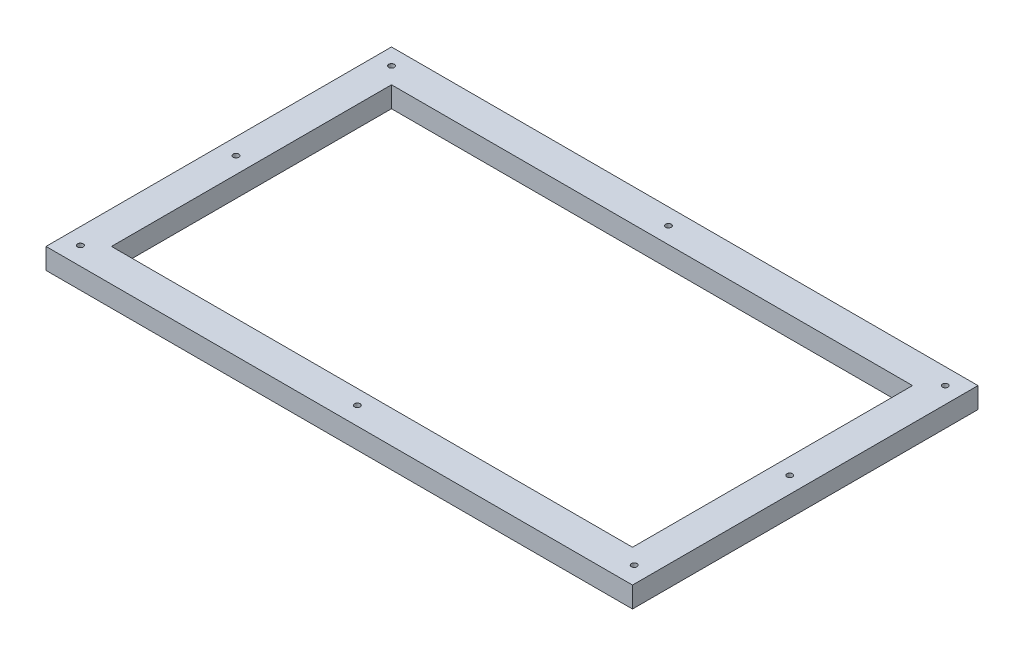
from build123d import *

# Parameters (mm, degrees)
SKETCH1_W                      = 358.27
SKETCH1_H                      = 211.05
BOSS_EXTRUDE1_DEPTH            = 12.7
SKETCH2_W                      = 318.27
SKETCH2_H                      = 171.05
CUT_EXTRUDE1_DEPTH             = 12.7
M3_CLEARANCE_HOLE1_D           = 3.4
M3_CLEARANCE_HOLE1_CSINK_D     = 3.45
M3_CLEARANCE_HOLE1_CSINK_ANGLE = 90


with BuildPart() as part:
    # Sketch1 → Boss-Extrude1 (new body)
    with BuildSketch(Plane(origin=(0, 0, 0), x_dir=(1, 0, 0), z_dir=(0, 1, 0))):
        Rectangle(SKETCH1_W, SKETCH1_H)
    extrude(amount=BOSS_EXTRUDE1_DEPTH)

    # Sketch2 → Cut-Extrude1 (cut)
    with BuildSketch(Plane(origin=(0, 12.7, 0), x_dir=(1, 0, 0), z_dir=(0, 1, 0))):
        Rectangle(SKETCH2_W, SKETCH2_H)
    extrude(amount=-CUT_EXTRUDE1_DEPTH, mode=Mode.SUBTRACT)

    # M3 Clearance Hole1 (through all)
    with Locations(Plane(origin=(0, 12.7, 0), x_dir=(1, 0, 0), z_dir=(0, 1, 0))):
        with Locations((-169.135, 95.525), (-169.135, 0.525), (-169.135, -94.475), (0, -94.475), (169.135, -94.475), (169.135, 0.525), (169.135, 95.525), (0, 95.525)):
            CounterSinkHole(M3_CLEARANCE_HOLE1_D / 2, M3_CLEARANCE_HOLE1_CSINK_D / 2, counter_sink_angle=M3_CLEARANCE_HOLE1_CSINK_ANGLE)


solid = part.part
